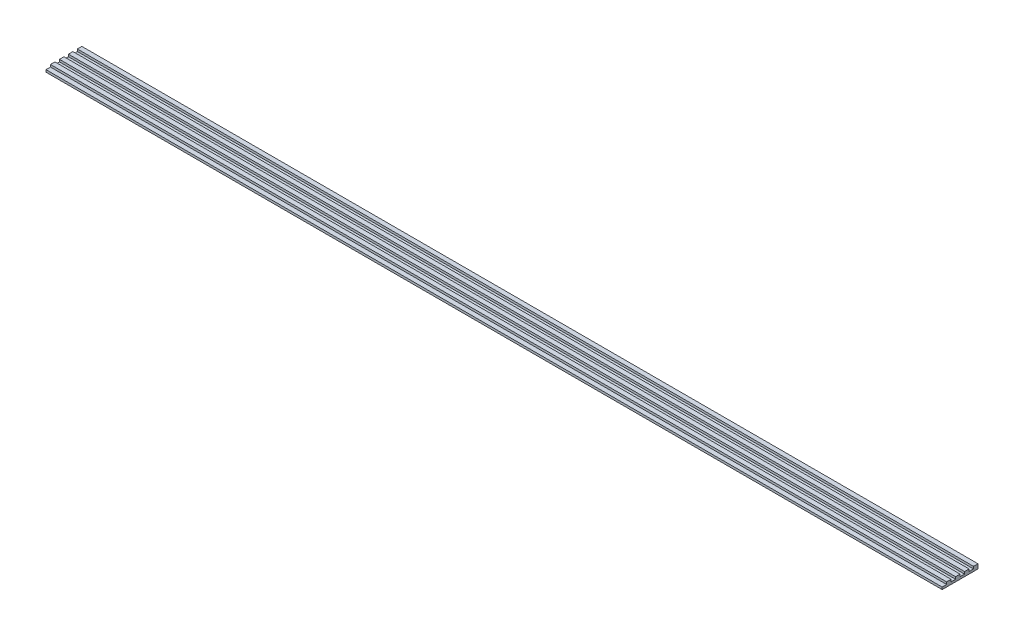
from build123d import *

# Parameters (mm, degrees)
SKETCH1_W           = 200
SKETCH1_H           = 8
BOSS_EXTRUDE1_DEPTH = 0.5
SKETCH2_W           = 200
SKETCH2_H           = 1
BOSS_EXTRUDE2_DEPTH = 0.5


with BuildPart() as part:
    # Sketch1 → Boss-Extrude1 (new body)
    with BuildSketch(Plane(origin=(0, 0, 0), x_dir=(1, 0, 0), z_dir=(0, 1, 0))):
        Rectangle(SKETCH1_W, SKETCH1_H)
    extrude(amount=BOSS_EXTRUDE1_DEPTH)

    # Sketch2 → Boss-Extrude2 (add)
    with BuildSketch(Plane(origin=(0, 0.5, 0), x_dir=(1, 0, 0), z_dir=(0, 1, 0))):
        with Locations((0, 3.5)):
            Rectangle(SKETCH2_W, SKETCH2_H)
        with Locations((0, 1.5)):
            Rectangle(SKETCH2_W, SKETCH2_H)
        with Locations((0, -0.5)):
            Rectangle(SKETCH2_W, SKETCH2_H)
        with Locations((0, -2.5)):
            Rectangle(SKETCH2_W, SKETCH2_H)
    extrude(amount=BOSS_EXTRUDE2_DEPTH)


solid = part.part
